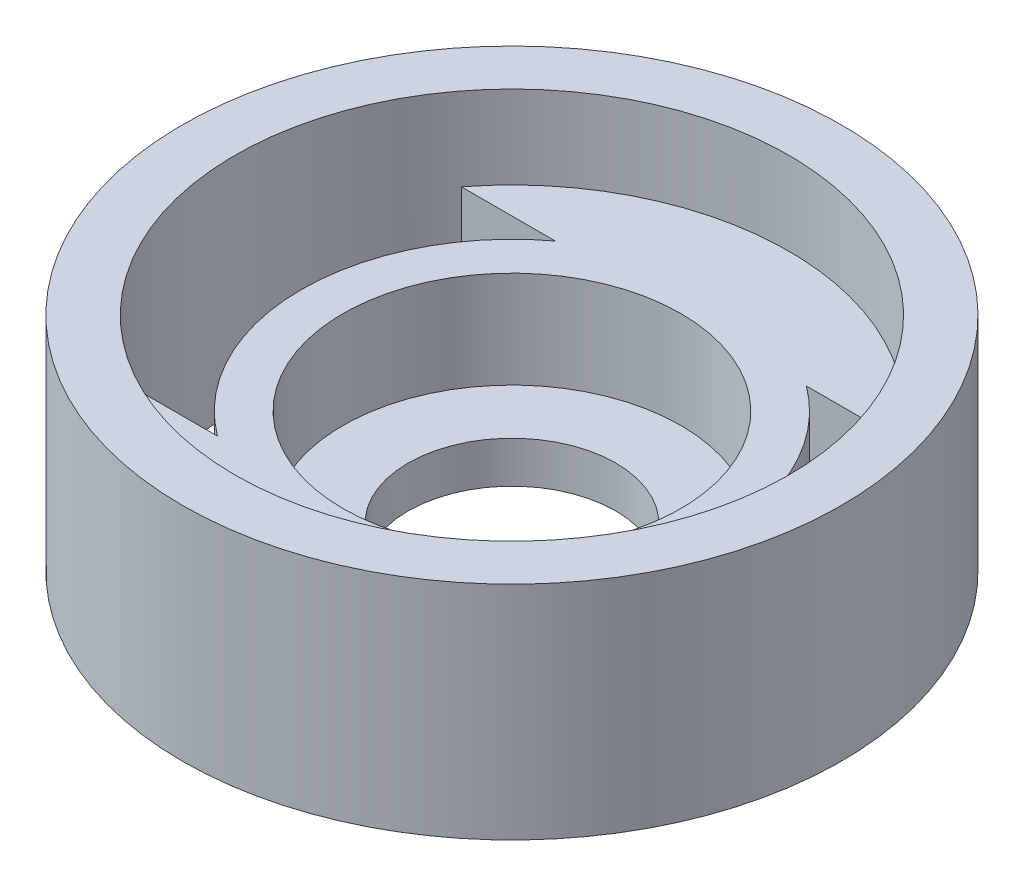
from build123d import *

# Parameters (mm, degrees)
SKETCH1_R           = 23.2
SKETCH1_R_2         = 12.2
BOSS_EXTRUDE1_DEPTH = 10
SKETCH2_R           = 12.2
BOSS_EXTRUDE2_DEPTH = 3
SKETCH3_R           = 7.5
CUT_EXTRUDE1_DEPTH  = 3
SKETCH4_R           = 23.2
SKETCH4_R_2         = 20
BOSS_EXTRUDE3_DEPTH = 6
CUT_EXTRUDE3_DEPTH  = 59
SKETCH8_R           = 23.8
SKETCH8_R_2         = 23.2
BOSS_EXTRUDE4_DEPTH = 16


with BuildPart() as part:
    # Sketch1 → Boss-Extrude1 (new body)
    with BuildSketch(Plane(origin=(0, 0, 0), x_dir=(1, 0, 0), z_dir=(0, 1, 0))):
        Circle(SKETCH1_R)
        Circle(SKETCH1_R_2, mode=Mode.SUBTRACT)
    extrude(amount=BOSS_EXTRUDE1_DEPTH)

    # Sketch2 → Boss-Extrude2 (add)
    with BuildSketch(Plane.XZ):
        Circle(SKETCH2_R)
    extrude(amount=-BOSS_EXTRUDE2_DEPTH)

    # Sketch3 → Cut-Extrude1 (cut)
    with BuildSketch(Plane(origin=(0, 3, 0), x_dir=(1, 0, 0), z_dir=(0, 1, 0))):
        Circle(SKETCH3_R)
    extrude(amount=-CUT_EXTRUDE1_DEPTH, mode=Mode.SUBTRACT)

    # Sketch4 → Boss-Extrude3 (add)
    with BuildSketch(Plane(origin=(0, 10, 0), x_dir=(1, 0, 0), z_dir=(0, 1, 0))):
        Circle(SKETCH4_R)
        Circle(SKETCH4_R_2, mode=Mode.SUBTRACT)
    extrude(amount=BOSS_EXTRUDE3_DEPTH)

    # Sketch6 → Cut-Extrude3 (cut)
    with BuildSketch(Plane(origin=(0, 10, 0), x_dir=(1, 0, 0), z_dir=(0, 1, 0))):
        with BuildLine():
            Line((15.848028, 12.2), (9.066422, 12.2))
            ThreePointArc((9.066422, 12.2), (15.2, 0), (9.066422, -12.2))
            Line((9.066422, -12.2), (15.848028, -12.2))
            ThreePointArc((15.848028, -12.2), (20, 0), (15.848028, 12.2))
        make_face()
        with BuildLine():
            ThreePointArc((-9.066422, -12.2), (-15.2, 0), (-9.066422, 12.2))
            Line((-9.066422, 12.2), (-15.848028, 12.2))
            ThreePointArc((-15.848028, 12.2), (-20, 0), (-15.848028, -12.2))
            Line((-15.848028, -12.2), (-9.066422, -12.2))
        make_face()
    extrude(amount=-CUT_EXTRUDE3_DEPTH, mode=Mode.SUBTRACT)

    # Sketch8 → Boss-Extrude4 (add)
    with BuildSketch(Plane(origin=(0, 16, 0), x_dir=(1, 0, 0), z_dir=(0, 1, 0))):
        Circle(SKETCH8_R)
        Circle(SKETCH8_R_2, mode=Mode.SUBTRACT)
    extrude(amount=-BOSS_EXTRUDE4_DEPTH)


solid = part.part
